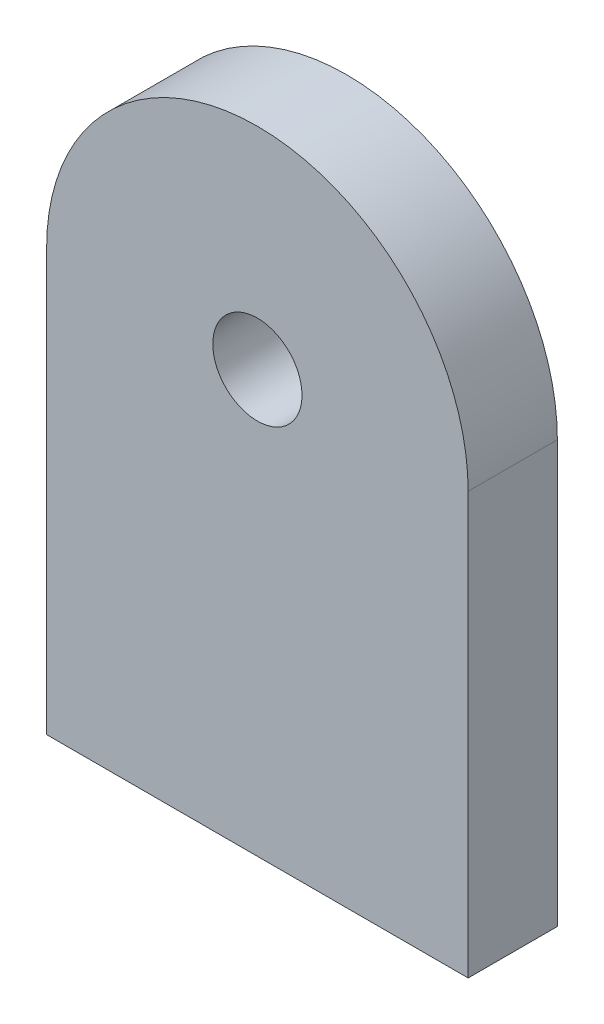
from build123d import *

# Parameters (mm, degrees)
MAIN_SHAPE_DEPTH                = 6.35
F_1_4_0_25_DIAMETER_HOLE1_D     = 6.35
F_1_4_0_25_DIAMETER_HOLE1_DEPTH = 18
F_1_4_0_25_DIAMETER_HOLE1_TIP   = 1.907732465


with BuildPart() as part:
    # Sketch1 → main shape (new body)
    with BuildSketch(Plane.XY):
        with BuildLine():
            Line((0, 0), (30, 0))
            Line((30, 0), (30, 30))
            ThreePointArc((30, 30), (15, 45), (0, 30))
            Line((0, 30), (0, 0))
        make_face()
    extrude(amount=MAIN_SHAPE_DEPTH)

    # 1/4 (0.25) Diameter Hole1
    with Locations(Plane.XY.offset(6.35)):
        with Locations((15, 30)):
            Hole(F_1_4_0_25_DIAMETER_HOLE1_D / 2, depth=F_1_4_0_25_DIAMETER_HOLE1_DEPTH)
            with Locations((0, 0, -(F_1_4_0_25_DIAMETER_HOLE1_DEPTH + F_1_4_0_25_DIAMETER_HOLE1_TIP / 2))):  # 118° drill point
                Cone(0, F_1_4_0_25_DIAMETER_HOLE1_D / 2, F_1_4_0_25_DIAMETER_HOLE1_TIP, mode=Mode.SUBTRACT)


solid = part.part
